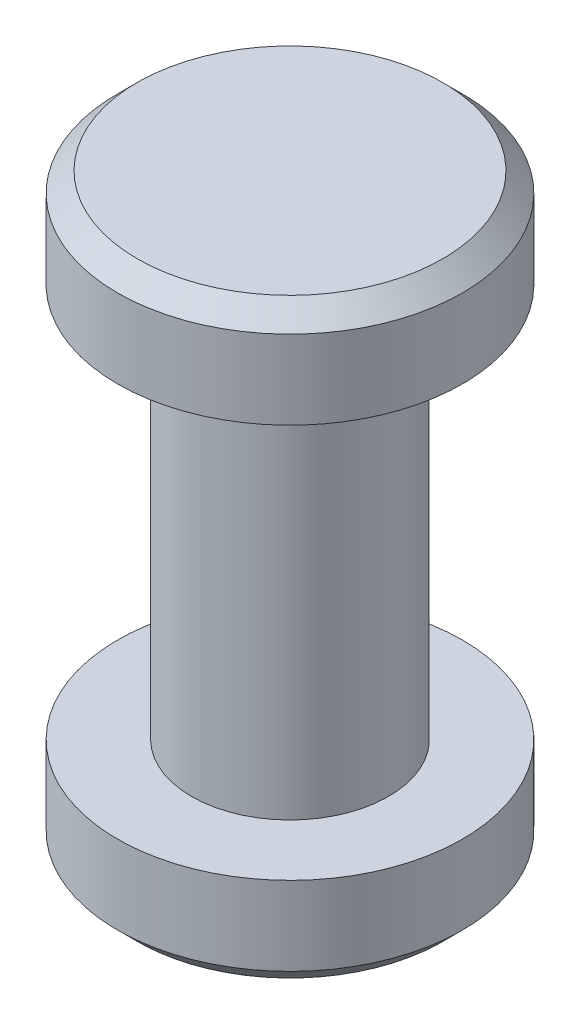
from build123d import *

# Parameters (mm, degrees)
SKETCH1_R           = 1
BOSS_EXTRUDE1_DEPTH = 4
SKETCH2_R           = 1.75
BOSS_EXTRUDE2_DEPTH = 1
CHAMFER1_SIZE       = 0.2
SKETCH3_R           = 1.75
BOSS_EXTRUDE3_DEPTH = 1
CHAMFER2_SIZE       = 0.2


with BuildPart() as part:
    # Sketch1 → Boss-Extrude1 (new body)
    with BuildSketch(Plane(origin=(0, 0, 0), x_dir=(1, 0, 0), z_dir=(0, 1, 0))):
        Circle(SKETCH1_R)
    extrude(amount=BOSS_EXTRUDE1_DEPTH)

    # Sketch2 → Boss-Extrude2 (add)
    with BuildSketch(Plane(origin=(0, 4, 0), x_dir=(1, 0, 0), z_dir=(0, 1, 0))):
        Circle(SKETCH2_R)
    extrude(amount=BOSS_EXTRUDE2_DEPTH)

    # Chamfer1
    chamfer1_edges = [part.edges().sort_by_distance(p)[0] for p in [
        (-1.75, 5, 0),
    ]]
    chamfer(chamfer1_edges, length=CHAMFER1_SIZE)

    # Sketch3 → Boss-Extrude3 (add)
    with BuildSketch(Plane.XZ):
        Circle(SKETCH3_R)
    extrude(amount=BOSS_EXTRUDE3_DEPTH)

    # Chamfer2
    chamfer2_edges = [part.edges().sort_by_distance(p)[0] for p in [
        (-1.75, -1, 0),
    ]]
    chamfer(chamfer2_edges, length=CHAMFER2_SIZE)


solid = part.part
